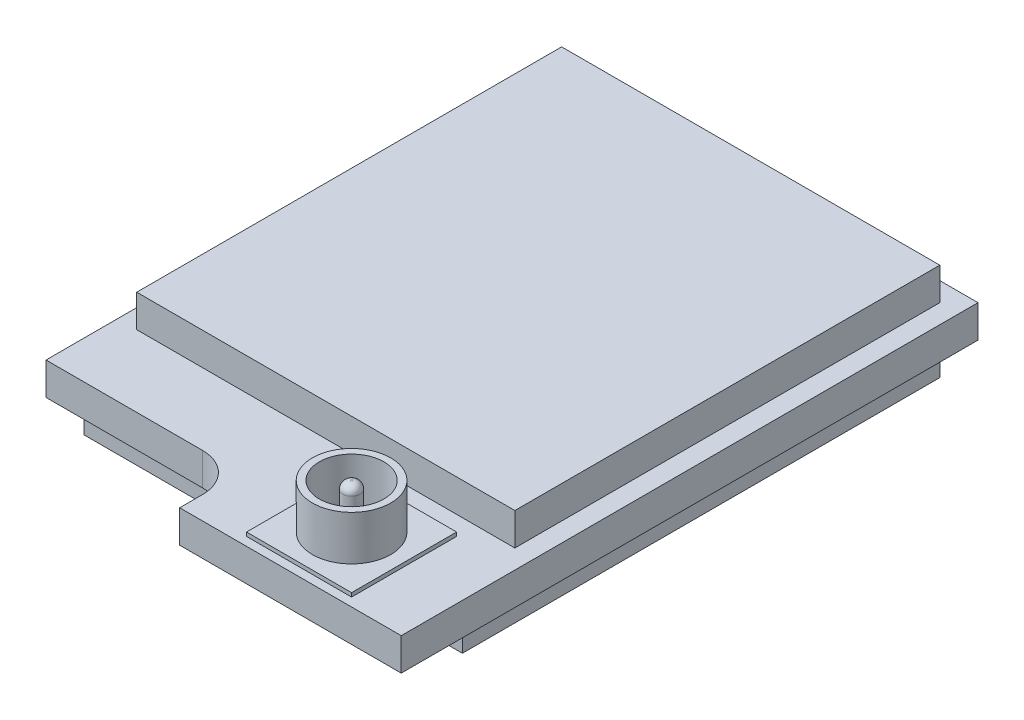
from build123d import *

# Parameters (mm, degrees)
BOSS_EXTRUDE1_DEPTH = 0.425
SKETCH2_W           = 2.75
SKETCH2_H           = 2.75
BOSS_EXTRUDE2_DEPTH = 0.1
BOSS_EXTRUDE3_START = -0.95
SKETCH3_R           = 1.025
SKETCH3_R_2         = 0.845
SKETCH3_R_3         = 0.225
BOSS_EXTRUDE3_DEPTH = 2.12
FILLET1_R           = 0.2
BOSS_EXTRUDE4_START = -0.85
SKETCH4_W           = 9.9
SKETCH4_H           = 12.5
BOSS_EXTRUDE4_DEPTH = 1.7
BOSS_EXTRUDE5_START = -0.85
SKETCH5_W           = 9.9
SKETCH5_H           = 11.125
BOSS_EXTRUDE5_DEPTH = 1.7


with BuildPart() as part:
    # Sketch1 → Boss-Extrude1 (new body, symmetric)
    with BuildSketch(Plane(origin=(0, 0, 0), x_dir=(1, 0, 0), z_dir=(0, 1, 0))):
        with BuildLine():
            Line((-5.45, -6.75), (-1.35, -6.75))
            ThreePointArc((-1.35, -6.75), (-0.642893219, -7.042893219), (-0.35, -7.75))
            Line((-0.35, -7.75), (-0.35, -8.35))
            Line((-0.35, -8.35), (5.45, -8.35))
            Line((5.45, -8.35), (5.45, -6.75))
            Line((5.45, -6.75), (5.45, 6.75))
            Line((5.45, 6.75), (-5.45, 6.75))
            Line((-5.45, 6.75), (-5.45, -6.75))
        make_face()
    extrude(amount=BOSS_EXTRUDE1_DEPTH, both=True)

    # Sketch2 → Boss-Extrude2 (add)
    with BuildSketch(Plane(origin=(0, 0.425, 0), x_dir=(1, 0, 0), z_dir=(0, 1, 0))):
        with Locations((2.55, -6.75)):
            Rectangle(SKETCH2_W, SKETCH2_H)
    extrude(amount=BOSS_EXTRUDE2_DEPTH)

    # Sketch3 → Boss-Extrude3 (add)
    with BuildSketch(Plane(origin=(0, 0.525, 0), x_dir=(1, 0, 0), z_dir=(0, 1, 0)).offset(BOSS_EXTRUDE3_START)):
        with Locations((2.55, -6.75)):
            Circle(SKETCH3_R)
        with Locations((2.55, -6.75)):
            Circle(SKETCH3_R_2, mode=Mode.SUBTRACT)
        with Locations((2.55, -6.75)):
            Circle(SKETCH3_R_3)
    extrude(amount=BOSS_EXTRUDE3_DEPTH)

    # Fillet1
    fillet1_edges = [part.edges().sort_by_distance(p)[0] for p in [
        (2.325, 1.695, 6.75),
    ]]
    fillet(fillet1_edges, radius=FILLET1_R)

    # Sketch4 → Boss-Extrude4 (add)
    with BuildSketch(Plane.XZ.offset(0.425).offset(BOSS_EXTRUDE4_START)):
        Rectangle(SKETCH4_W, SKETCH4_H)
    extrude(amount=BOSS_EXTRUDE4_DEPTH)

    # Sketch5 → Boss-Extrude5 (add)
    with BuildSketch(Plane(origin=(0, 0.425, 0), x_dir=(1, 0, 0), z_dir=(0, 1, 0)).offset(BOSS_EXTRUDE5_START)):
        with Locations((0, 0.6875)):
            Rectangle(SKETCH5_W, SKETCH5_H)
    extrude(amount=BOSS_EXTRUDE5_DEPTH)


solid = part.part
